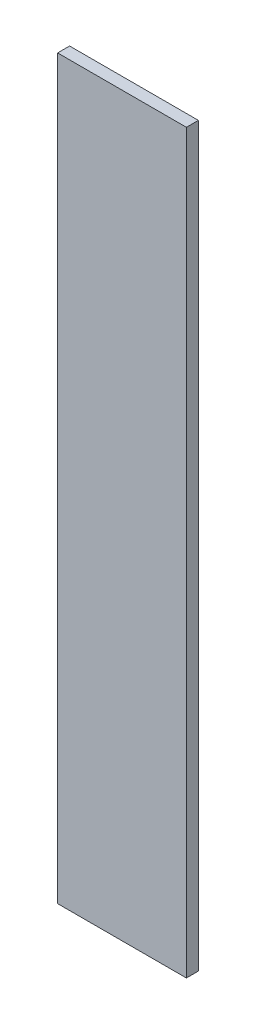
from build123d import *

# Parameters (mm, degrees)
ESQUISSE1_W        = 53.75
ESQUISSE1_H        = 307.5
BOSS_EXTRU_4_DEPTH = 5


with BuildPart() as part:
    # Esquisse1 → Boss.-Extru.4 (new body)
    with BuildSketch(Plane.XY):
        with Locations((-4.0375, -132.88125)):
            Rectangle(ESQUISSE1_W, ESQUISSE1_H)
    extrude(amount=BOSS_EXTRU_4_DEPTH)


solid = part.part
